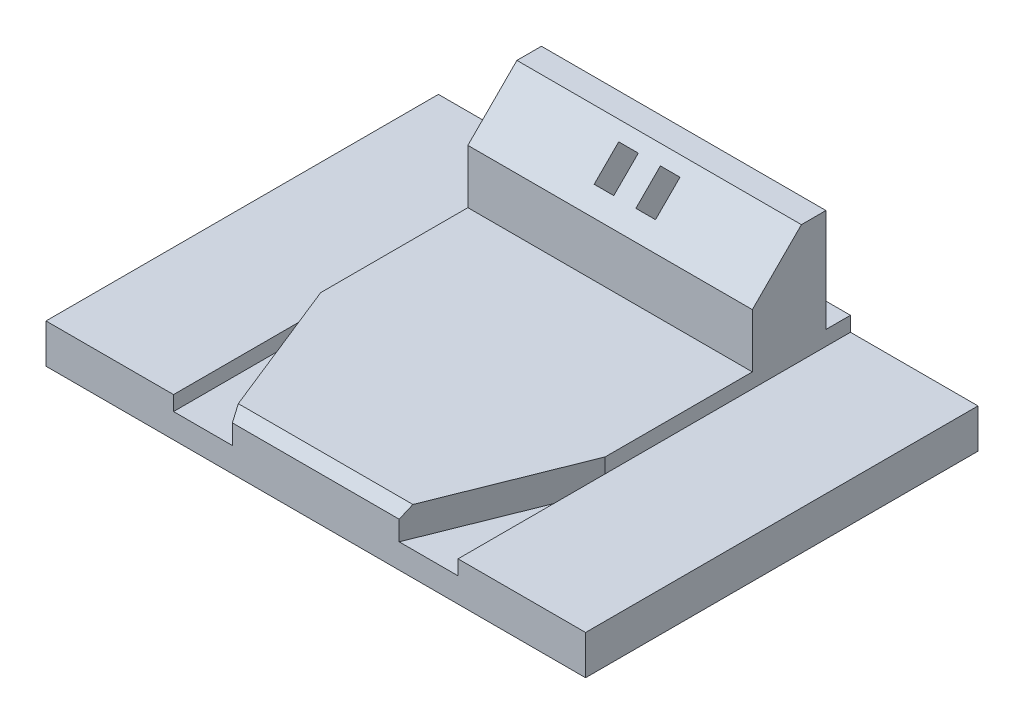
from build123d import *

# Parameters (mm, degrees)
SKETCH_1_W          = 110
SKETCH_1_H          = 80
EXTRUDE_1_DEPTH     = 8
SKETCH_3_W          = 58
SKETCH_3_H          = 80
EXTRUDE_2_DEPTH     = 9
CUT_EXTRUDE_2_DEPTH = 6
CHAMFER_5_SIZE      = 2
SKETCH_10_W         = 58
SKETCH_10_H         = 15
EXTRUDE_5_DEPTH     = 30
CHAMFER_9_SIZE      = 10
SKETCH_11_W         = 4
SKETCH_11_H         = 12
CUT_EXTRUDE_6_DEPTH = 30
SKETCH_12_W         = 25
SKETCH_12_H         = 25
CUT_EXTRUDE_7_DEPTH = 9
SKETCH_13_W         = 12
SKETCH_13_H         = 3
EXTRUDE_6_DEPTH     = 5
SKETCH_14_W         = 25
SKETCH_14_H         = 5.959996218
EXTRUDE_7_DEPTH     = 1


with BuildPart() as part:
    # 草图1 → 凸台-拉伸1 (new body)
    with BuildSketch(Plane(origin=(0, 0, 0), x_dir=(1, 0, 0), z_dir=(0, 1, 0))):
        Rectangle(SKETCH_1_W, SKETCH_1_H)
    extrude(amount=EXTRUDE_1_DEPTH)

    # 草图3 → 凸台-拉伸2 (add)
    with BuildSketch(Plane(origin=(0, 2, 0), x_dir=(1, 0, 0), z_dir=(0, 1, 0))):
        Rectangle(SKETCH_3_W, SKETCH_3_H)
    extrude(amount=EXTRUDE_2_DEPTH)

    # 草图4 → 切除-拉伸2 (cut)
    with BuildSketch(Plane(origin=(0, 11, 0), x_dir=(1, 0, 0), z_dir=(0, 1, 0))):
        Polygon((-29, -10), (-29, -40), (-17, -40), align=None)
        Polygon((17, -40), (29, -10), (29, -40), align=None)
    extrude(amount=-CUT_EXTRUDE_2_DEPTH, mode=Mode.SUBTRACT)

    # 倒角5
    chamfer_5_edges = [part.edges().sort_by_distance(p)[0] for p in [
        (0, 11, 40),
    ]]
    chamfer(chamfer_5_edges, length=CHAMFER_5_SIZE)

    # 草图10 → 凸台-拉伸5 (add)
    with BuildSketch(Plane(origin=(0, 2, 0), x_dir=(1, 0, 0), z_dir=(0, 1, 0))):
        with Locations((0, 27.5)):
            Rectangle(SKETCH_10_W, SKETCH_10_H)
    extrude(amount=EXTRUDE_5_DEPTH)

    # 倒角9
    chamfer_9_edges = [part.edges().sort_by_distance(p)[0] for p in [
        (0, 32, -20),
    ]]
    chamfer(chamfer_9_edges, length=CHAMFER_9_SIZE)

    # 草图11 → 切除-拉伸6 (cut)
    with BuildSketch(Plane.XZ):
        with Locations((-4.25, -29)):
            Rectangle(SKETCH_11_W, SKETCH_11_H)
        with Locations((4.25, -29)):
            Rectangle(SKETCH_11_W, SKETCH_11_H)
    extrude(amount=-CUT_EXTRUDE_6_DEPTH, mode=Mode.SUBTRACT)

    # 草图12 → 切除-拉伸7 (cut)
    with BuildSketch(Plane.XZ):
        with Locations((0, -22.5)):
            Rectangle(SKETCH_12_W, SKETCH_12_H)
    extrude(amount=-CUT_EXTRUDE_7_DEPTH, mode=Mode.SUBTRACT)

    # 草图13 → 凸台-拉伸6 (add)
    with BuildSketch(Plane.XZ.offset(-9)):
        with Locations((0, -19.5)):
            Rectangle(SKETCH_13_W, SKETCH_13_H)
    extrude(amount=EXTRUDE_6_DEPTH)

    # 草图14 → 凸台-拉伸7 (add)
    with BuildSketch(Plane.XZ.offset(-9)):
        with Locations((0, -12.979998109)):
            Rectangle(SKETCH_14_W, SKETCH_14_H)
    extrude(amount=EXTRUDE_7_DEPTH)


solid = part.part
